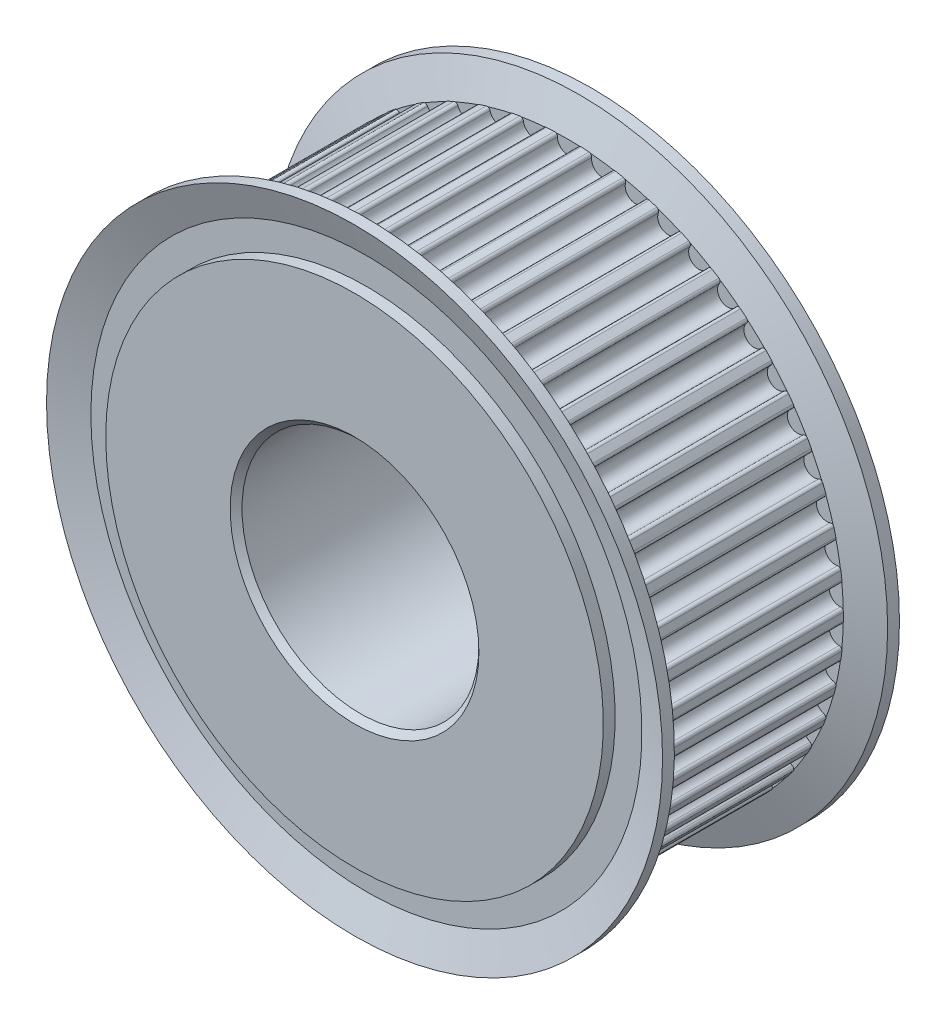
from build123d import *

# Parameters (mm, degrees)
SKETCH1_R                  = 23.875
BASE_DEPTH                 = 8
TOOTHCUT_DEPTH             = 9
TEETHCUTS_COUNT            = 50
BORE_AND_KEYWAY_DEPTH      = 11
BORE_AND_KEYWAY_DEPTH_BACK = 11
BORECHAMFER_SIZE           = 0.25
SKETCH8_R                  = 10
CUT_EXTRUDE1_DEPTH         = 21
CHAMFER1_SIZE              = 0.5


with BuildPart() as part:
    # Sketch1 → Base (new body, symmetric)
    with BuildSketch(Plane.XY):
        Circle(SKETCH1_R)
    extrude(amount=BASE_DEPTH, both=True)

    # Sketch2 → ToothCut (cut, symmetric)
    with BuildSketch(Plane.XY):
        with BuildLine():
            Line((-1.461222555, 23.239106128), (-1.498247305, 23.82794326))
            ThreePointArc((-1.498247305, 23.82794326), (0.00087808, 23.874999984), (1.5, 23.82783299))
            Line((1.5, 23.82783299), (1.462931937, 23.238998583))
            ThreePointArc((1.462931937, 23.238998583), (1.297459585, 23.248824134), (1.13192148, 23.257471461))
            ThreePointArc((1.13192148, 23.257471461), (0.945511035, 23.187027474), (0.869820233, 23.002685097))
            ThreePointArc((0.869820233, 23.002685097), (0, 22.115), (-0.869820233, 23.002685097))
            ThreePointArc((-0.869820233, 23.002685097), (-0.945511035, 23.187027474), (-1.13192148, 23.257471461))
            ThreePointArc((-1.13192148, 23.257471461), (-1.296604534, 23.248871837), (-1.461222555, 23.239106128))
        make_face()
    toothcut = extrude(amount=TOOTHCUT_DEPTH, both=True, mode=Mode.SUBTRACT)

    # TeethCuts: ToothCut ×50 about axis
    teethcuts_axis = Axis((0, 0, 0), (0, 0, 1))
    for i in range(1, TEETHCUTS_COUNT):
        add(toothcut.rotate(teethcuts_axis, i * 360 / TEETHCUTS_COUNT), mode=Mode.SUBTRACT)

    # Sketch6 → Flange (revolve)
    with BuildSketch(Plane(origin=(0, 0, 0), x_dir=(0, 0, -1), z_dir=(1, 0, 0))):
        Polygon((-8, 23.257471461), (-9, 26), (-10, 26), (-9, 23.257471461), (-9, 21), (-10, 21), (-10, 0), (-8, 0), align=None)
        Polygon((8, 0), (8, 23.257471461), (9, 26), (10, 26), (9, 23.257471461), (9, 21), (10, 21), (10, 0), align=None)
    revolve(axis=Axis((0, 0, -8), (0, 0, 1)))

    # Sketch7 → Bore and Keyway (cut, two sides)
    with BuildSketch(Plane.XY) as bore_and_keyway_sk:
        with BuildLine():
            Line((-2.485, 9.044064104), (2.485, 9.044064104))
            Line((2.485, 9.044064104), (2.485, 6.544064104))
            ThreePointArc((2.485, 6.544064104), (0, -7), (-2.485, 6.544064104))
            Line((-2.485, 6.544064104), (-2.485, 9.044064104))
        make_face()
    extrude(amount=BORE_AND_KEYWAY_DEPTH, mode=Mode.SUBTRACT)
    extrude(bore_and_keyway_sk.sketch, amount=-BORE_AND_KEYWAY_DEPTH_BACK, mode=Mode.SUBTRACT)

    # BoreChamfer
    borechamfer_edges = [part.edges().sort_by_distance(p)[0] for p in [
        (-2.485, 7.794064104, -10),
        (0, 9.044064104, -10),
        (2.485, 7.794064104, -10),
        (0, -7, -10),
        (-2.485, 7.794064104, 10),
        (0, -7, 10),
        (2.485, 7.794064104, 10),
        (0, 9.044064104, 10),
    ]]
    chamfer(borechamfer_edges, length=BORECHAMFER_SIZE)

    # Sketch8 → Cut-Extrude1 (cut, through all)
    with BuildSketch(Plane.XY.offset(10)):
        Circle(SKETCH8_R)
    extrude(amount=-CUT_EXTRUDE1_DEPTH, mode=Mode.SUBTRACT)

    # Chamfer1
    chamfer1_edges = [part.edges().sort_by_distance(p)[0] for p in [
        (-10, 0, -10),
        (-10, 0, 10),
    ]]
    chamfer(chamfer1_edges, length=CHAMFER1_SIZE)


solid = part.part
